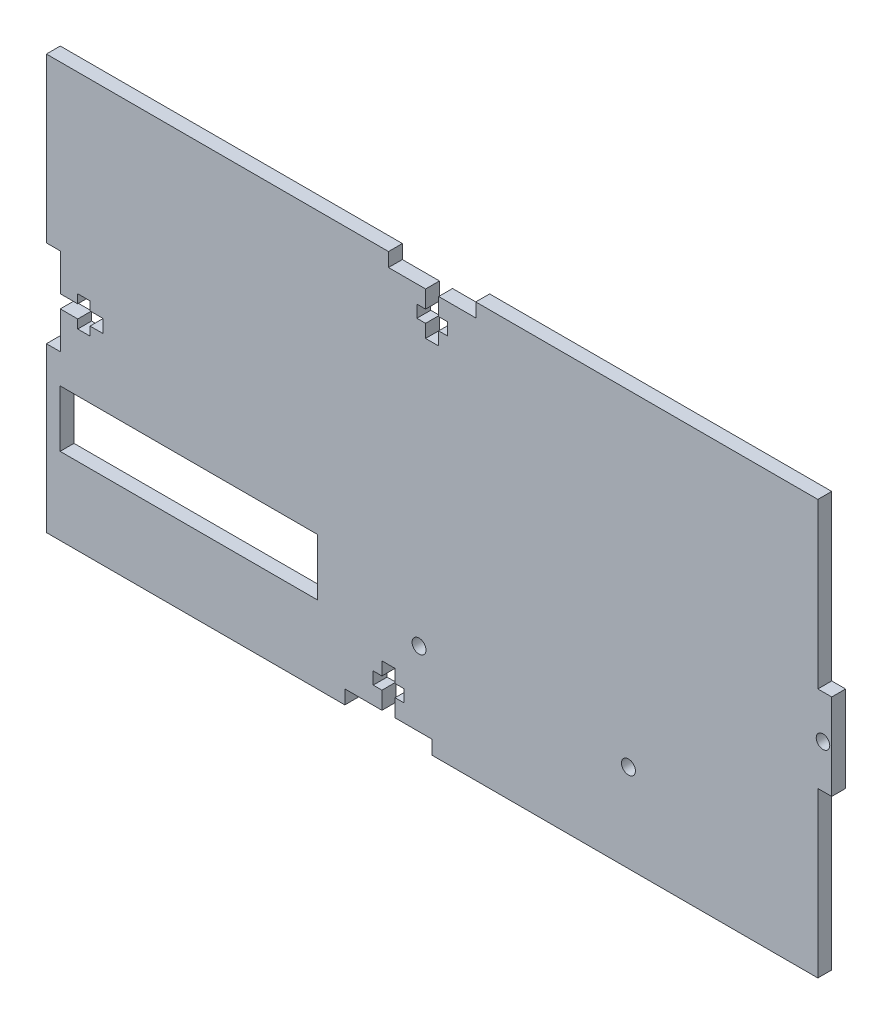
from build123d import *

# Parameters (mm, degrees)
SKETCH1_W               = 180
SKETCH1_H               = 95
BOSS_EXTRUDE1_DEPTH     = 3.18
SKETCH2_W               = 3.18
SKETCH2_H               = 37.625
CUT_EXTRUDE1_DEPTH      = 1
CUT_EXTRUDE1_DEPTH_BACK = 4.18
SKETCH3_R               = 1.55
CUT_EXTRUDE2_DEPTH      = 1
CUT_EXTRUDE2_DEPTH_BACK = 4.18
CUT_EXTRUDE3_DEPTH      = 1
CUT_EXTRUDE3_DEPTH_BACK = 4.18
CUT_EXTRUDE4_DEPTH      = 1
CUT_EXTRUDE4_DEPTH_BACK = 4.18
CUT_EXTRUDE5_DEPTH      = 1
CUT_EXTRUDE5_DEPTH_BACK = 4.18
SKETCH8_W               = 58.994769075
SKETCH8_H               = 13
CUT_EXTRUDE6_DEPTH      = 1
CUT_EXTRUDE6_DEPTH_BACK = 4.18
SKETCH9_R               = 1.6
CUT_EXTRUDE7_DEPTH      = 1
CUT_EXTRUDE7_DEPTH_BACK = 4.18


with BuildPart() as part:
    # Sketch1 → Boss-Extrude1 (new body)
    with BuildSketch(Plane.XY):
        Rectangle(SKETCH1_W, SKETCH1_H)
    extrude(amount=BOSS_EXTRUDE1_DEPTH)

    # Sketch2 → Cut-Extrude1 (cut, two sides)
    with BuildSketch(Plane.XY.offset(3.18)) as cut_extrude1_sk:
        with Locations((88.41, 28.6875)):
            Rectangle(SKETCH2_W, SKETCH2_H)
        with Locations((88.41, -28.6875)):
            Rectangle(SKETCH2_W, SKETCH2_H)
    extrude(amount=CUT_EXTRUDE1_DEPTH, mode=Mode.SUBTRACT)
    extrude(cut_extrude1_sk.sketch, amount=-CUT_EXTRUDE1_DEPTH_BACK, mode=Mode.SUBTRACT)

    # Sketch3 → Cut-Extrude2 (cut, two sides)
    with BuildSketch(Plane.XY.offset(3.18)) as cut_extrude2_sk:
        with Locations((88, 0)):
            Circle(SKETCH3_R)
    extrude(amount=CUT_EXTRUDE2_DEPTH, mode=Mode.SUBTRACT)
    extrude(cut_extrude2_sk.sketch, amount=-CUT_EXTRUDE2_DEPTH_BACK, mode=Mode.SUBTRACT)

    # Sketch5 → Cut-Extrude3 (cut, two sides)
    with BuildSketch(Plane(origin=(0, 0, 0), x_dir=(-1, 0, 0), z_dir=(0, 0, -1))) as cut_extrude3_sk:
        Polygon((11.59, 47.5), (-8.41, 47.5), (-8.41, 44.32), (0.09, 44.32), (0.09, 40.32), (-1.91, 40.32), (-1.91, 37.5), (0.09, 37.5), (0.09, 34.5), (3.09, 34.5), (3.09, 37.5), (5.09, 37.5), (5.09, 40.32), (3.09, 40.32), (3.09, 44.32), (11.59, 44.32), align=None)
    extrude(amount=CUT_EXTRUDE3_DEPTH, mode=Mode.SUBTRACT)
    extrude(cut_extrude3_sk.sketch, amount=-CUT_EXTRUDE3_DEPTH_BACK, mode=Mode.SUBTRACT)

    # Sketch6 → Cut-Extrude4 (cut, two sides)
    with BuildSketch(Plane.XY.offset(3.18)) as cut_extrude4_sk:
        Polygon((-21.59, -47.5), (-1.59, -47.5), (-1.59, -44.32), (-10.09, -44.32), (-10.09, -40.32), (-8.09, -40.32), (-8.09, -37.5), (-10.09, -37.5), (-10.09, -34.5), (-13.09, -34.5), (-13.09, -37.5), (-15.09, -37.5), (-15.09, -40.32), (-13.09, -40.32), (-13.09, -44.32), (-21.59, -44.32), align=None)
    extrude(amount=CUT_EXTRUDE4_DEPTH, mode=Mode.SUBTRACT)
    extrude(cut_extrude4_sk.sketch, amount=-CUT_EXTRUDE4_DEPTH_BACK, mode=Mode.SUBTRACT)

    # Sketch7 → Cut-Extrude5 (cut, two sides)
    with BuildSketch(Plane.XY.offset(3.18)) as cut_extrude5_sk:
        Polygon((-90, 10), (-86.82, 10), (-86.82, 1.5), (-82.82, 1.5), (-82.82, 3.5), (-80, 3.5), (-80, 1.5), (-77, 1.5), (-77, -1.5), (-80, -1.5), (-80, -3.5), (-82.82, -3.5), (-82.82, -1.5), (-86.82, -1.5), (-86.82, -10), (-90, -10), align=None)
    extrude(amount=CUT_EXTRUDE5_DEPTH, mode=Mode.SUBTRACT)
    extrude(cut_extrude5_sk.sketch, amount=-CUT_EXTRUDE5_DEPTH_BACK, mode=Mode.SUBTRACT)

    # Sketch8 → Cut-Extrude6 (cut, two sides)
    with BuildSketch(Plane.XY.offset(3.18)) as cut_extrude6_sk:
        with Locations((-57.357372864, -23.3)):
            Rectangle(SKETCH8_W, SKETCH8_H)
    extrude(amount=CUT_EXTRUDE6_DEPTH, mode=Mode.SUBTRACT)
    extrude(cut_extrude6_sk.sketch, amount=-CUT_EXTRUDE6_DEPTH_BACK, mode=Mode.SUBTRACT)

    # Sketch9 → Cut-Extrude7 (cut, two sides)
    with BuildSketch(Plane.XY.offset(3.18)) as cut_extrude7_sk:
        with Locations((-4.59, -27.32)):
            Circle(SKETCH9_R)
        with Locations((43.41, -27.32)):
            Circle(SKETCH9_R)
    extrude(amount=CUT_EXTRUDE7_DEPTH, mode=Mode.SUBTRACT)
    extrude(cut_extrude7_sk.sketch, amount=-CUT_EXTRUDE7_DEPTH_BACK, mode=Mode.SUBTRACT)


solid = part.part
